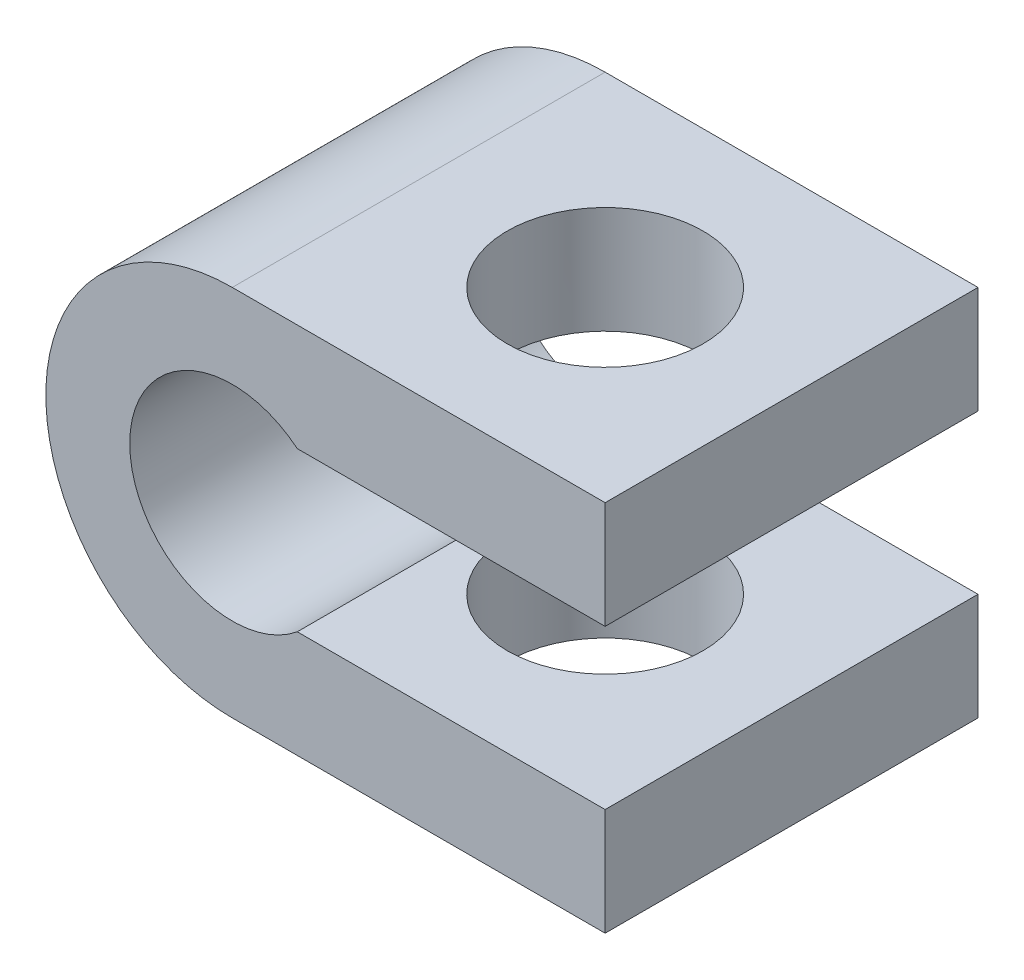
from build123d import *

# Parameters (mm, degrees)
BOSS_EXTRUDE1_DEPTH     = 12
SKETCH2_R               = 3.15
CUT_EXTRUDE1_DEPTH      = 7
CUT_EXTRUDE1_DEPTH_BACK = 7


with BuildPart() as part:
    # Sketch1 → Boss-Extrude1 (new body)
    with BuildSketch(Plane.XY):
        with BuildLine():
            Line((0, 6), (12, 6))
            Line((12, 6), (12, 2.552710574))
            Line((12, 2.552710574), (2.091331807, 2.552710574))
            ThreePointArc((2.091331807, 2.552710574), (-3.3, 0), (2.091331807, -2.552710574))
            Line((2.091331807, -2.552710574), (12, -2.552710574))
            Line((12, -2.552710574), (12, -6))
            Line((12, -6), (0, -6))
            ThreePointArc((0, -6), (-6, 0), (0, 6))
        make_face()
    extrude(amount=BOSS_EXTRUDE1_DEPTH)

    # Sketch2 → Cut-Extrude1 (cut, two sides)
    with BuildSketch(Plane(origin=(0, 0, 0), x_dir=(1, 0, 0), z_dir=(0, 1, 0))) as cut_extrude1_sk:
        with Locations((6, -6)):
            Circle(SKETCH2_R)
    extrude(amount=CUT_EXTRUDE1_DEPTH, mode=Mode.SUBTRACT)
    extrude(cut_extrude1_sk.sketch, amount=-CUT_EXTRUDE1_DEPTH_BACK, mode=Mode.SUBTRACT)


solid = part.part
